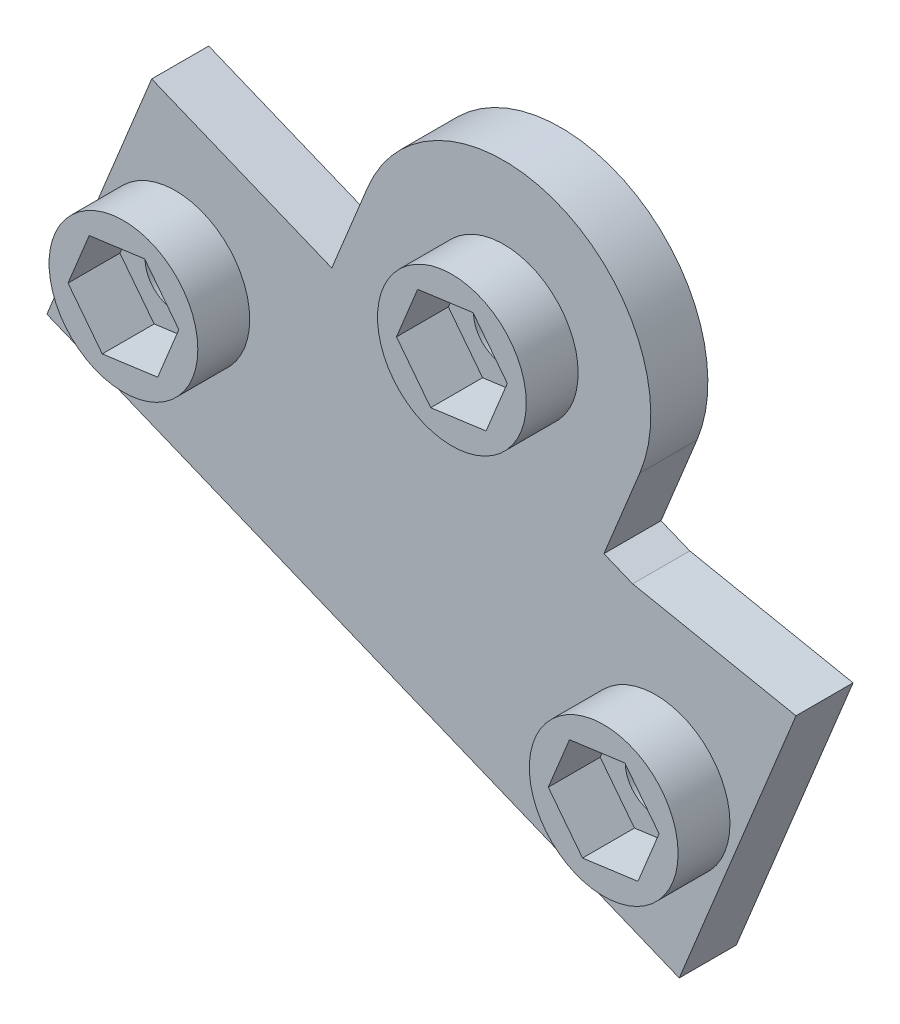
from build123d import *

# Parameters (mm, degrees)
SKETCH1_R           = 1.75
BOSS_EXTRUDE1_DEPTH = 3.3
SKETCH3_R           = 4.3
BOSS_EXTRUDE3_DEPTH = 3


with BuildPart() as part:
    # Sketch1 → Boss-Extrude1 (new body)
    with BuildSketch(Plane.XY):
        with BuildLine():
            ThreePointArc((-51.5, -14.365), (-58.360069791, -6.024698512), (-67.867206803, -11.146761798))
            ThreePointArc((-67.867206803, -11.146761798), (-68.49399131, -14.045450902), (-68.08677112, -16.983039888))
            ThreePointArc((-68.08677112, -16.983039888), (-63.218238202, -22.232206803), (-56.066588393, -21.900135907))
            ThreePointArc((-56.066588393, -21.900135907), (-53.717281627, -20.090159373), (-52.132793197, -17.583238202))
            ThreePointArc((-52.132793197, -17.583238202), (-51.659698512, -16.004930209), (-51.5, -14.365))
        make_face()
        with Locations((-60, -14.365)):
            Circle(SKETCH1_R, mode=Mode.SUBTRACT)
        with BuildLine():
            ThreePointArc((-68.08677112, -16.983039888), (-68.49399131, -14.045450902), (-67.867206803, -11.146761798))
            Line((-67.867206803, -11.146761798), (-69.943886559, -16.223349695))
            Line((-69.943886559, -16.223349695), (-68.08677112, -16.983039888))
        make_face()
        with BuildLine():
            Line((-68.08677112, -16.983039888), (-69.943886559, -16.223349695))
            Line((-69.943886559, -16.223349695), (-80.356366151, -11.963916781))
            Line((-80.356366151, -11.963916781), (-86.414226296, -26.772776645))
            Line((-86.414226296, -26.772776645), (-49.854853507, -41.728118878))
            Line((-49.854853507, -41.728118878), (-43.103796568, -25.224691306))
            Line((-43.103796568, -25.224691306), (-52.547252782, -23.339790487))
            Line((-52.547252782, -23.339790487), (-54.209472954, -22.659826099))
            Line((-54.209472954, -22.659826099), (-56.066588393, -21.900135907))
            ThreePointArc((-56.066588393, -21.900135907), (-63.218238202, -22.232206803), (-68.08677112, -16.983039888))
        make_face()
        with Locations((-51.222303707, -32.525261715)):
            Circle(SKETCH1_R, mode=Mode.SUBTRACT)
        with Locations((-78.988915951, -21.166773943)):
            Circle(SKETCH1_R, mode=Mode.SUBTRACT)
        with BuildLine():
            Line((-54.209472954, -22.659826099), (-52.132793197, -17.583238202))
            ThreePointArc((-52.132793197, -17.583238202), (-53.717281627, -20.090159373), (-56.066588393, -21.900135907))
            Line((-56.066588393, -21.900135907), (-54.209472954, -22.659826099))
        make_face()
    extrude(amount=BOSS_EXTRUDE1_DEPTH)

    # Sketch3 → Boss-Extrude3 (add)
    with BuildSketch(Plane.XY.offset(3.3)):
        with Locations((-78.988915951, -21.166773943)):
            Circle(SKETCH3_R)
        Polygon((-75.785301718, -20.730667104), (-77.764788436, -18.174309213), (-80.96840267, -18.610416053), (-82.192530185, -21.602880783), (-80.213043466, -24.159238673), (-77.009429233, -23.723131834), align=None, mode=Mode.SUBTRACT)
        with Locations((-60, -14.365)):
            Circle(SKETCH3_R)
        Polygon((-63.203614234, -14.80110684), (-61.224127515, -17.35746473), (-58.020513281, -16.92135789), (-56.796385766, -13.92889316), (-58.775872485, -11.37253527), (-61.979486719, -11.80864211), align=None, mode=Mode.SUBTRACT)
        with Locations((-51.222303707, -32.525261715)):
            Circle(SKETCH3_R)
        Polygon((-54.42591794, -32.961368555), (-52.446431222, -35.517726445), (-49.242816988, -35.081619606), (-48.018689473, -32.089154876), (-49.998176192, -29.532796985), (-53.201790425, -29.968903825), align=None, mode=Mode.SUBTRACT)
    extrude(amount=BOSS_EXTRUDE3_DEPTH)


solid = part.part
